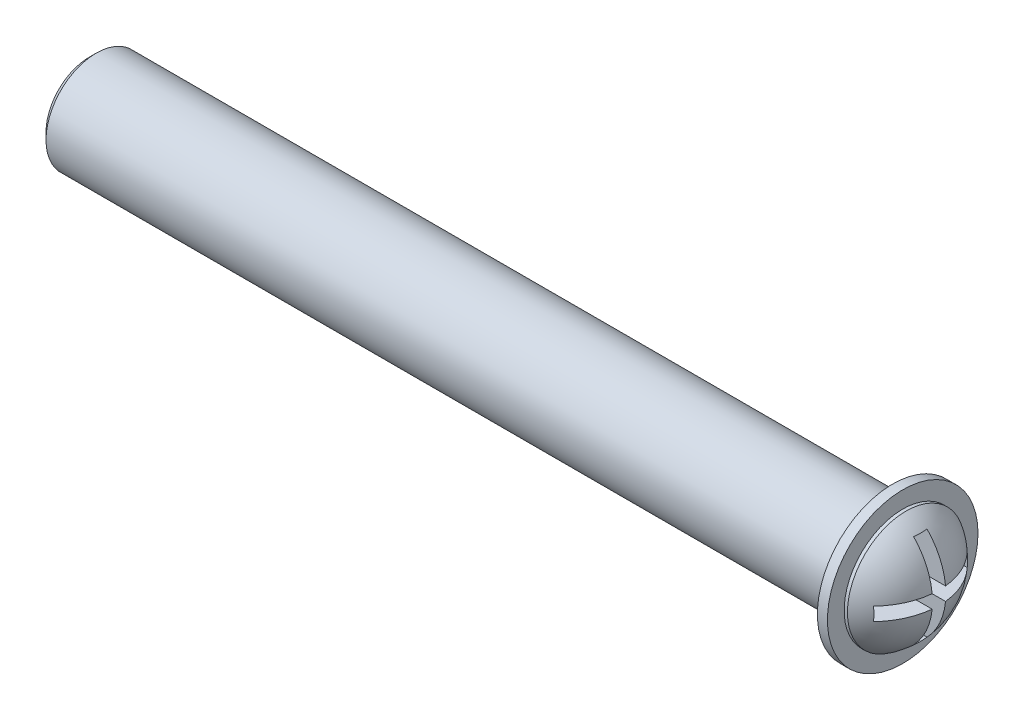
from build123d import *

# Parameters (mm, degrees)
SKETCH_1_R          = 2.25
EXTRUDE_1_DEPTH     = 0.3
SKETCH_2_R          = 1.5
EXTRUDE_3_DEPTH     = 24
SKETCH_6_R          = 1.75
EXTRUDE_4_DEPTH     = 0.1
DOME_1_FACE_RADIUS  = 1.75
DOME_1_HEIGHT       = 1
CUT_EXTRUDE_2_DEPTH = 2
CHAMFER_1_SIZE      = 0.2


with BuildPart() as part:
    # Sketch 1 → Extrude 1 (new body)
    with BuildSketch(Plane(origin=(0, 0, 0), x_dir=(0, 0, -1), z_dir=(1, 0, 0))):
        Circle(SKETCH_1_R)
    extrude(amount=EXTRUDE_1_DEPTH)

    # Sketch 2 → Extrude 3 (add)
    with BuildSketch(Plane.ZY):
        Circle(SKETCH_2_R)
    extrude(amount=EXTRUDE_3_DEPTH)

    # Sketch 6 → Extrude 4 (add)
    with BuildSketch(Plane(origin=(0.3, 0, 0), x_dir=(0, 0, -1), z_dir=(1, 0, 0))):
        Circle(SKETCH_6_R)
    extrude(amount=EXTRUDE_4_DEPTH)

    # Dome 1: a dome of height H over a round flat face of radius A is a cap of a sphere of radius (A * A + H * H) / (2 * H)
    dome_1_r = (DOME_1_FACE_RADIUS * DOME_1_FACE_RADIUS + DOME_1_HEIGHT * DOME_1_HEIGHT) / (2 * DOME_1_HEIGHT)
    dome_1_base = Plane((0.4, 0, 0), z_dir=(1, 0, 0))
    with Locations(dome_1_base.offset(DOME_1_HEIGHT - dome_1_r)):
        dome_1_ball = Sphere(dome_1_r, mode=Mode.PRIVATE)
    add(split(dome_1_ball, bisect_by=dome_1_base, keep=Keep.TOP, mode=Mode.PRIVATE))

    # Sketch 5 → Cut-Extrude 2 (cut)
    with BuildSketch(Plane(origin=(0, 0, 0), x_dir=(0, 0, -1), z_dir=(1, 0, 0))):
        Polygon((0.2, 0.2), (1.4, 0.2), (1.4, -0.2), (0.2, -0.2), (0.2, -1.4), (-0.2, -1.4), (-0.2, -0.2), (-1.4, -0.2), (-1.4, 0.2), (-0.2, 0.2), (-0.2, 1.4), (0.2, 1.4), align=None)
    extrude(amount=CUT_EXTRUDE_2_DEPTH, mode=Mode.SUBTRACT)

    # Chamfer 1
    chamfer_1_edges = [part.edges().sort_by_distance(p)[0] for p in [
        (-24, 0, -1.5),
    ]]
    chamfer(chamfer_1_edges, length=CHAMFER_1_SIZE)


solid = part.part
